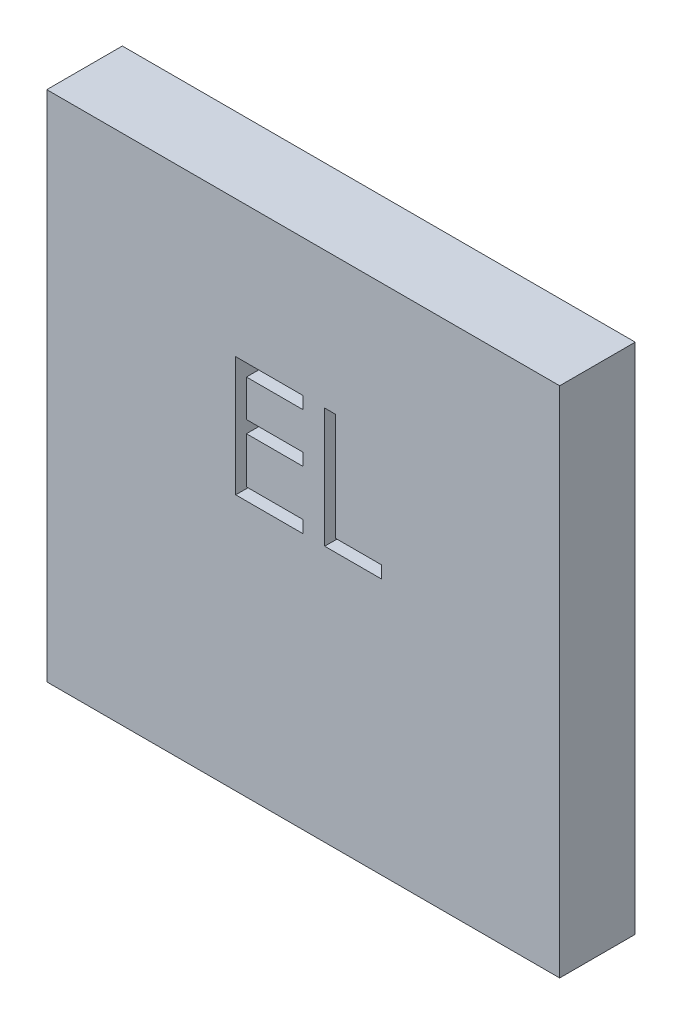
from build123d import *

# Parameters (mm, degrees)
SKETCH1_W           = 15
SKETCH1_H           = 15
BOSS_EXTRUDE1_DEPTH = 2.21


with BuildPart() as part:
    # Sketch1 → Boss-Extrude1 (new body)
    with BuildSketch(Plane.XY):
        with Locations((7.5, 7.5)):
            Rectangle(SKETCH1_W, SKETCH1_H)
        Polygon((5.525641026, 11), (7.5, 11), (7.5, 10.641025641), (5.83974359, 10.641025641), (5.83974359, 9.564102564), (7.5, 9.564102564), (7.5, 9.205128205), (5.83974359, 9.205128205), (5.83974359, 7.858974359), (7.5, 7.858974359), (7.5, 7.5), (5.525641026, 7.5), align=None, mode=Mode.SUBTRACT)
        Polygon((8.128205128, 11), (8.442307692, 11), (8.442307692, 7.858974359), (9.788461538, 7.858974359), (9.788461538, 7.5), (8.128205128, 7.5), align=None, mode=Mode.SUBTRACT)
    extrude(amount=BOSS_EXTRUDE1_DEPTH)


solid = part.part
